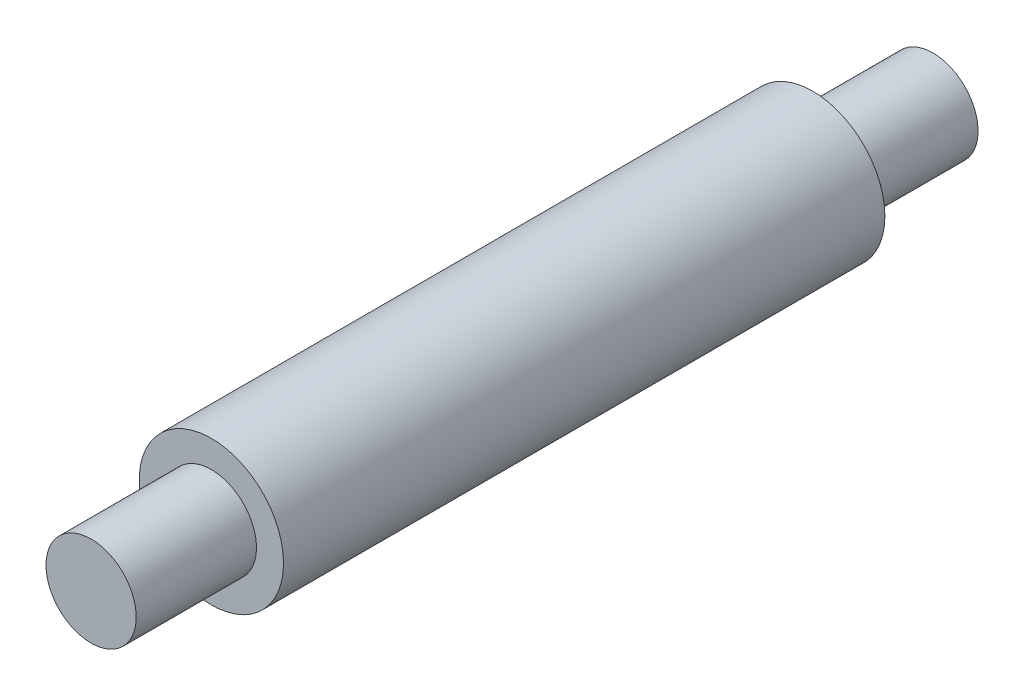
from build123d import *

# Parameters (mm, degrees)
SKETCH1_R           = 24
BOSS_EXTRUDE1_DEPTH = 200
SKETCH2_R           = 15
BOSS_EXTRUDE2_DEPTH = 40
LPATTERN1_COUNT     = 2
LPATTERN1_PITCH     = 240


with BuildPart() as part:
    # Sketch1 → Boss-Extrude1 (new body)
    with BuildSketch(Plane.XY):
        Circle(SKETCH1_R)
    extrude(amount=BOSS_EXTRUDE1_DEPTH)

    # Sketch2 → Boss-Extrude2 (add)
    with BuildSketch(Plane(origin=(0, 0, 0), x_dir=(-1, 0, 0), z_dir=(0, 0, -1))):
        Circle(SKETCH2_R)
    boss_extrude2 = extrude(amount=BOSS_EXTRUDE2_DEPTH)

    # LPattern1: Boss-Extrude2 ×2
    with Locations(*[(0, 0, i * LPATTERN1_PITCH) for i in range(1, LPATTERN1_COUNT)]):
        add(boss_extrude2)


solid = part.part
